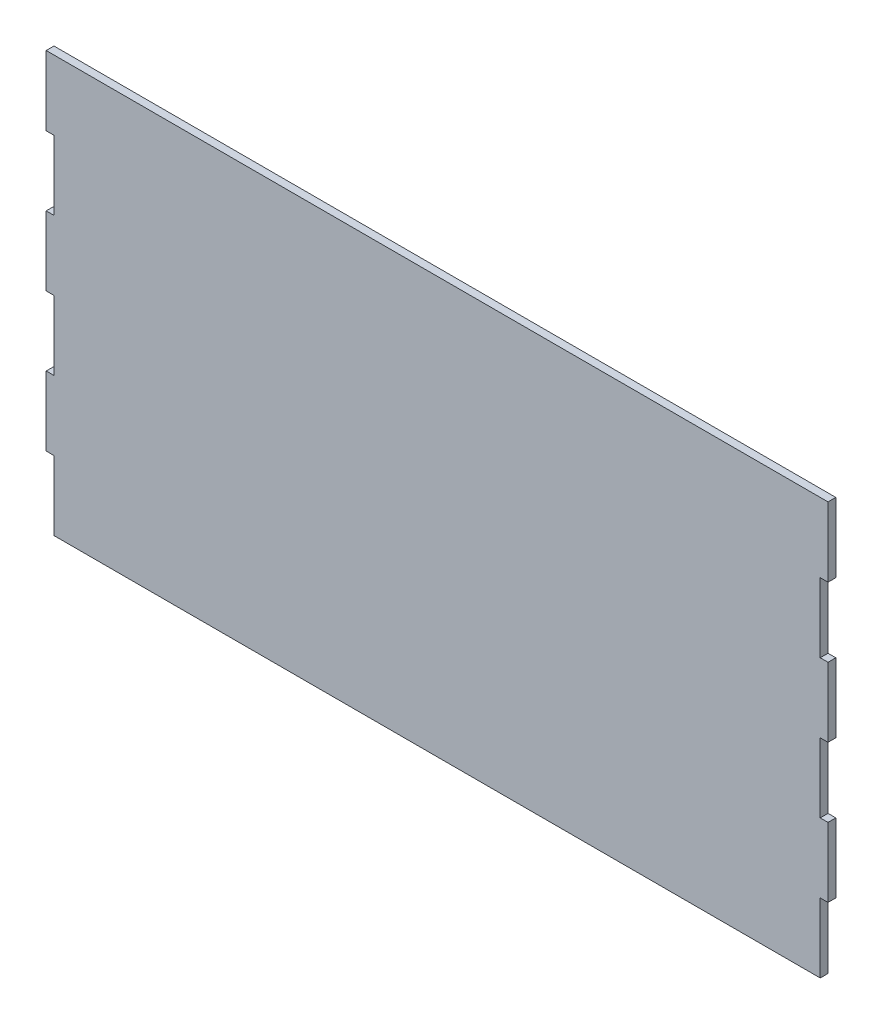
from build123d import *

# Parameters (mm, degrees)
BOSS_EXTRUDE2_DEPTH = 3


with BuildPart() as part:
    # Sketch2 → Boss-Extrude2 (new body)
    with BuildSketch(Plane.XY):
        Polygon((-147.537163877, -23.257209728), (147.537163877, -23.257209728), (147.537163877, 3.442790272), (150.537163877, 3.442790272), (150.537163877, 30.142790272), (147.537163877, 30.142790272), (147.537163877, 56.842790272), (150.537163877, 56.842790272), (150.537163877, 83.542790272), (147.537163877, 83.542790272), (147.537163877, 110.242790272), (150.537163877, 110.242790272), (150.537163877, 137.021276107), (147.537163877, 137.021276107), (-147.537163877, 137.021276107), (-150.537163877, 137.021276107), (-150.537163877, 110.242790272), (-147.537163877, 110.242790272), (-147.537163877, 83.542790272), (-150.537163877, 83.542790272), (-150.537163877, 56.842790272), (-147.537163877, 56.842790272), (-147.537163877, 30.142790272), (-150.537163877, 30.142790272), (-150.537163877, 3.442790272), (-147.537163877, 3.442790272), align=None)
    extrude(amount=BOSS_EXTRUDE2_DEPTH)


solid = part.part
